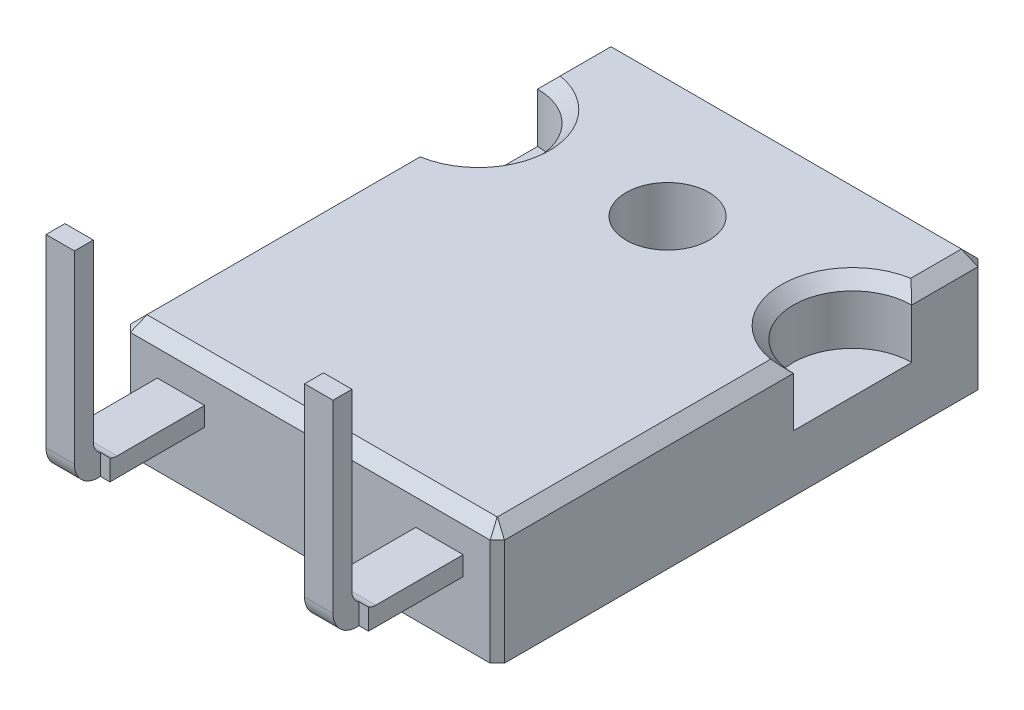
from build123d import *

# Parameters (mm, degrees)
SKETCH_1_R          = 1.75
EXTRUDE_1_DEPTH     = 2.6
SKETCH_1_3_W        = 15.8
SKETCH_1_3_H        = 20.6
SKETCH_1_3_R        = 1.75
EXTRUDE_2_DEPTH     = 2.4
EXTRUDE_START       = 0.2
SKETCH_1_4_W        = 1.2
SKETCH_1_4_H        = 0.3
SKETCH_1_4_H_2      = 0.8
EXTRUDE_3_DEPTH     = 0.8
SKETCH_1_5_W        = 1.2
SKETCH_1_5_H        = 0.8
EXTRUDE_4_DEPTH     = 8.8
FILLET_1_R          = 1
FILLET_2_R          = 1
FILLET_3_R          = 0.6
FILLET_4_R          = 0.6
CHAMFER_1_SIZE      = 0.3
CHAMFER_2_SIZE      = 0.5
SKETCH_2_W          = 13.8
SKETCH_2_H          = 18.6
SKETCH_2_R          = 1.75
CUT_EXTRUDE_1_DEPTH = 1.5
EXTRUDE_START_2     = -1.5
SKETCH_2_3_W        = 13.8
SKETCH_2_3_H        = 18.6
SKETCH_2_3_R        = 1.75
EXTRUDE_5_DEPTH     = 1.5


with BuildPart() as part:
    # Эскиз1 → Бобышка-Вытянуть1 (new body)
    with BuildSketch(Plane(origin=(0, 0, 0), x_dir=(1, 0, 0), z_dir=(0, 1, 0))):
        with BuildLine():
            Line((6.46, -10.3), (7.9, -10.3))
            Line((7.9, -10.3), (7.9, 2.2))
            ThreePointArc((7.9, 2.2), (5.4, 4.7), (7.9, 7.2))
            Line((7.9, 7.2), (7.9, 10.3))
            Line((7.9, 10.3), (-7.9, 10.3))
            Line((-7.9, 10.3), (-7.9, 7.2))
            ThreePointArc((-7.9, 7.2), (-5.4, 4.7), (-7.9, 2.2))
            Line((-7.9, 2.2), (-7.9, -10.3))
            Line((-7.9, -10.3), (-6.46, -10.3))
            Line((-6.46, -10.3), (-4.46, -10.3))
            Line((-4.46, -10.3), (4.46, -10.3))
            Line((4.46, -10.3), (6.46, -10.3))
        make_face()
        with Locations((0, 4.79)):
            Circle(SKETCH_1_R, mode=Mode.SUBTRACT)
    extrude(amount=EXTRUDE_1_DEPTH)

    # Эскиз1<3> → Бобышка-Вытянуть2 (add)
    with BuildSketch(Plane(origin=(0, 0, 0), x_dir=(1, 0, 0), z_dir=(0, 1, 0))):
        Rectangle(SKETCH_1_3_W, SKETCH_1_3_H)
        with Locations((0, 4.79)):
            Circle(SKETCH_1_3_R, mode=Mode.SUBTRACT)
    extrude(amount=-EXTRUDE_2_DEPTH)

    # Фаска1
    chamfer_1_edges = [part.edges().sort_by_distance(p)[0] for p in [
        (7.9, 0.1, 10.3),
        (-7.9, 0.1, 10.3),
        (-7.9, 0.1, -10.3),
        (7.9, 0.1, -10.3),
    ]]
    chamfer(chamfer_1_edges, length=CHAMFER_1_SIZE)

    # Фаска2
    chamfer_2_edges = [part.edges().sort_by_distance(p)[0] for p in [
        (5.4, 2.6, -4.7),
        (7.9, 2.6, -8.6),
        (-7.9, 2.6, -8.6),
        (-5.4, 2.6, -4.7),
        (0, 2.6, 10.3),
        (-7.9, 2.6, 3.9),
        (7.9, 2.6, 3.9),
        (0, 2.6, -10.3),
        (7.75, 2.6, 10.15),
        (7.75, 2.6, -10.15),
        (-7.75, 2.6, -10.15),
        (-7.75, 2.6, 10.15),
    ]]
    chamfer(chamfer_2_edges, length=CHAMFER_2_SIZE)

    # Эскиз2 → Вырез-Вытянуть1 (cut)
    with BuildSketch(Plane.XZ.offset(2.4)):
        Rectangle(SKETCH_2_W, SKETCH_2_H)
        with Locations((0, -4.79)):
            Circle(SKETCH_2_R, mode=Mode.SUBTRACT)
    extrude(amount=-CUT_EXTRUDE_1_DEPTH, mode=Mode.SUBTRACT)


with BuildPart() as body_2:
    # Эскиз1<4> → Бобышка-Вытянуть3 (new body)
    with BuildSketch(Plane(origin=(0, 0, 0), x_dir=(1, 0, 0), z_dir=(0, 1, 0)).offset(EXTRUDE_START)):
        Polygon((-4.46, -14.3), (-4.46, -10.3), (-6.46, -10.3), (-6.46, -14.3), (-6.06, -14.3), (-4.86, -14.3), align=None)
        with Locations((-5.46, -14.45)):
            Rectangle(SKETCH_1_4_W, SKETCH_1_4_H)
        with Locations((-5.46, -15)):
            Rectangle(SKETCH_1_4_W, SKETCH_1_4_H_2)
        Polygon((6.46, -14.3), (6.46, -10.3), (4.46, -10.3), (4.46, -14.3), (4.86, -14.3), (6.06, -14.3), align=None)
        with Locations((5.46, -14.45)):
            Rectangle(SKETCH_1_4_W, SKETCH_1_4_H)
        with Locations((5.46, -15)):
            Rectangle(SKETCH_1_4_W, SKETCH_1_4_H_2)
    extrude(amount=EXTRUDE_3_DEPTH)

    # Эскиз1<5> → Бобышка-Вытянуть4 (add)
    with BuildSketch(Plane(origin=(0, 0, 0), x_dir=(1, 0, 0), z_dir=(0, 1, 0)).offset(EXTRUDE_START)):
        with Locations((-5.46, -15)):
            Rectangle(SKETCH_1_5_W, SKETCH_1_5_H)
        with Locations((5.46, -15)):
            Rectangle(SKETCH_1_5_W, SKETCH_1_5_H)
    extrude(amount=EXTRUDE_4_DEPTH)

    # Скругление1
    fillet_1_edges = [body_2.edges().sort_by_distance(p)[0] for p in [
        (-5.46, 0.2, 15.4),
    ]]
    fillet(fillet_1_edges, radius=FILLET_1_R)

    # Скругление2
    fillet_2_edges = [body_2.edges().sort_by_distance(p)[0] for p in [
        (5.46, 0.2, 15.4),
    ]]
    fillet(fillet_2_edges, radius=FILLET_2_R)

    # Скругление3
    fillet_3_edges = [body_2.edges().sort_by_distance(p)[0] for p in [
        (-5.46, 1, 14.6),
    ]]
    fillet(fillet_3_edges, radius=FILLET_3_R)

    # Скругление4
    fillet_4_edges = [body_2.edges().sort_by_distance(p)[0] for p in [
        (5.46, 1, 14.6),
    ]]
    fillet(fillet_4_edges, radius=FILLET_4_R)


with BuildPart() as body_3:
    # Эскиз2<3> → Бобышка-Вытянуть5 (new body)
    with BuildSketch(Plane.XZ.offset(2.4).offset(EXTRUDE_START_2)):
        Rectangle(SKETCH_2_3_W, SKETCH_2_3_H)
        with Locations((0, -4.79)):
            Circle(SKETCH_2_3_R, mode=Mode.SUBTRACT)
    extrude(amount=EXTRUDE_5_DEPTH)


solid = Compound([part.part, body_2.part, body_3.part])
